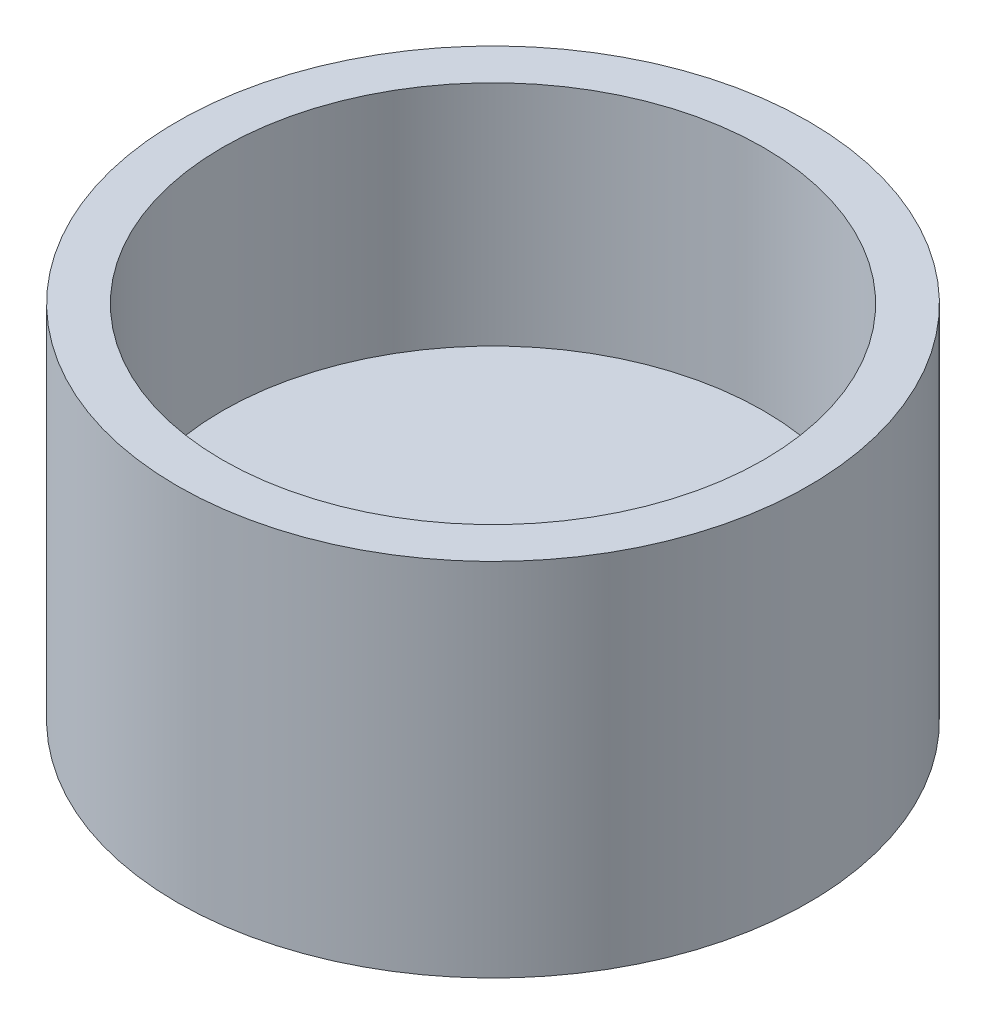
from build123d import *

# Parameters (mm, degrees)
SKETCH1_R           = 22.225
BOSS_EXTRUDE1_DEPTH = 6.35
SKETCH2_R           = 22.225
SKETCH2_R_2         = 19.05
BOSS_EXTRUDE2_DEPTH = 19.05
SKETCH3_R           = 19.05
SKETCH3_R_2         = 2.75
BOSS_EXTRUDE3_DEPTH = 3


with BuildPart() as part:
    # Sketch1 → Boss-Extrude1 (new body)
    with BuildSketch(Plane(origin=(0, 0, 0), x_dir=(1, 0, 0), z_dir=(0, 1, 0))):
        Circle(SKETCH1_R)
        Polygon((4.730817752, 7.253920553), (-3.9166706, 7.723968631), (-8.647488352, 0.470048077), (-4.730817752, -7.253920553), (3.9166706, -7.723968631), (8.647488352, -0.470048077), align=None, mode=Mode.SUBTRACT)
    extrude(amount=BOSS_EXTRUDE1_DEPTH)

    # Sketch2 → Boss-Extrude2 (add)
    with BuildSketch(Plane(origin=(0, 6.35, 0), x_dir=(1, 0, 0), z_dir=(0, 1, 0))):
        Circle(SKETCH2_R)
        Circle(SKETCH2_R_2, mode=Mode.SUBTRACT)
    extrude(amount=BOSS_EXTRUDE2_DEPTH)

    # Sketch3 → Boss-Extrude3 (add)
    with BuildSketch(Plane(origin=(0, 6.35, 0), x_dir=(1, 0, 0), z_dir=(0, 1, 0))):
        Circle(SKETCH3_R)
        Circle(SKETCH3_R_2, mode=Mode.SUBTRACT)
    extrude(amount=BOSS_EXTRUDE3_DEPTH)


solid = part.part
